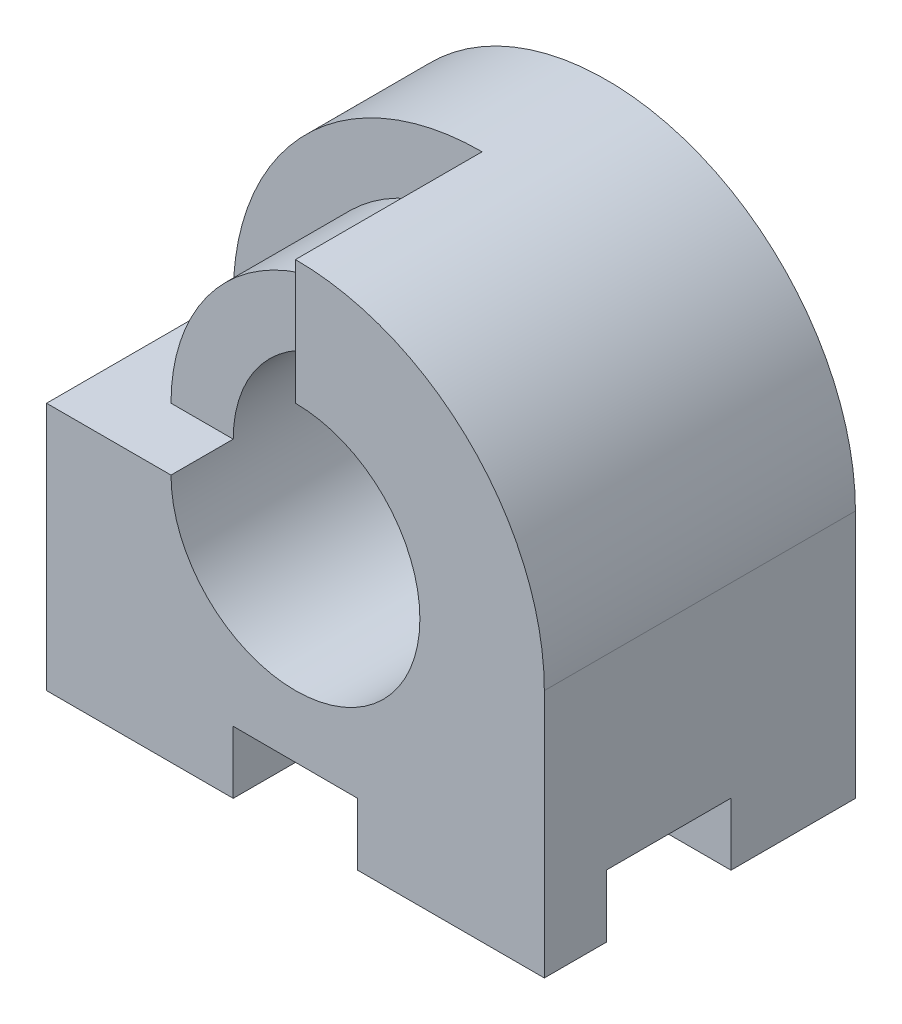
from build123d import *

# Parameters (mm, degrees)
SKETCH2_R           = 2
BOSS_EXTRUDE1_DEPTH = 2
BOSS_EXTRUDE2_DEPTH = 2
SKETCH4_W           = 3
SKETCH4_H           = 1.003544002
BOSS_EXTRUDE3_DEPTH = 1


with BuildPart() as part:
    # Sketch2 → Boss-Extrude1 (new body)
    with BuildSketch(Plane.XY):
        with BuildLine():
            Line((0, 0), (3, 0))
            Line((3, 0), (3, 1))
            Line((3, 1), (5, 1))
            Line((5, 1), (5, 0))
            Line((5, 0), (8, 0))
            Line((8, 0), (8, 4))
            ThreePointArc((8, 4), (4, 8), (0, 4))
            Line((0, 4), (0, 0))
        make_face()
        with Locations((4, 4)):
            Circle(SKETCH2_R, mode=Mode.SUBTRACT)
    extrude(amount=BOSS_EXTRUDE1_DEPTH)

    # Sketch3 → Boss-Extrude2 (add)
    with BuildSketch(Plane.XY.offset(2)):
        with BuildLine():
            Line((4, 8), (4, 7))
            ThreePointArc((4, 7), (1.878679656, 6.121320344), (1, 4))
            Line((1, 4), (0, 4))
            Line((0, 4), (0, 1.003544002))
            Line((0, 1.003544002), (8, 1.003544002))
            Line((8, 1.003544002), (8, 4))
            ThreePointArc((8, 4), (6.828427125, 6.828427125), (4, 8))
        make_face()
        with BuildLine():
            ThreePointArc((6, 4), (4, 2), (2, 4))
            ThreePointArc((2, 4), (2.585786438, 5.414213562), (4, 6))
            ThreePointArc((4, 6), (5.414213562, 5.414213562), (6, 4))
        make_face(mode=Mode.SUBTRACT)
    extrude(amount=BOSS_EXTRUDE2_DEPTH)

    # Sketch4 → Boss-Extrude3 (add)
    with BuildSketch(Plane.XY.offset(4)):
        with BuildLine():
            Line((1, 4), (0, 4))
            Line((0, 4), (0, 1.003544002))
            Line((0, 1.003544002), (3, 1.003544002))
            Line((3, 1.003544002), (8, 1.003544002))
            Line((8, 1.003544002), (8, 4))
            ThreePointArc((8, 4), (6.828427125, 6.828427125), (4, 8))
            Line((4, 8), (4, 7))
            Line((4, 7), (4, 6))
            ThreePointArc((4, 6), (5.414213562, 5.414213562), (6, 4))
            ThreePointArc((6, 4), (4, 2), (2, 4))
            Line((2, 4), (1, 4))
        make_face()
        with Locations((1.5, 0.501772001)):
            Rectangle(SKETCH4_W, SKETCH4_H)
        Polygon((8, 1.003544002), (3, 1.003544002), (5, 1), (5, 0), (8, 0), align=None)
    extrude(amount=BOSS_EXTRUDE3_DEPTH)


solid = part.part
